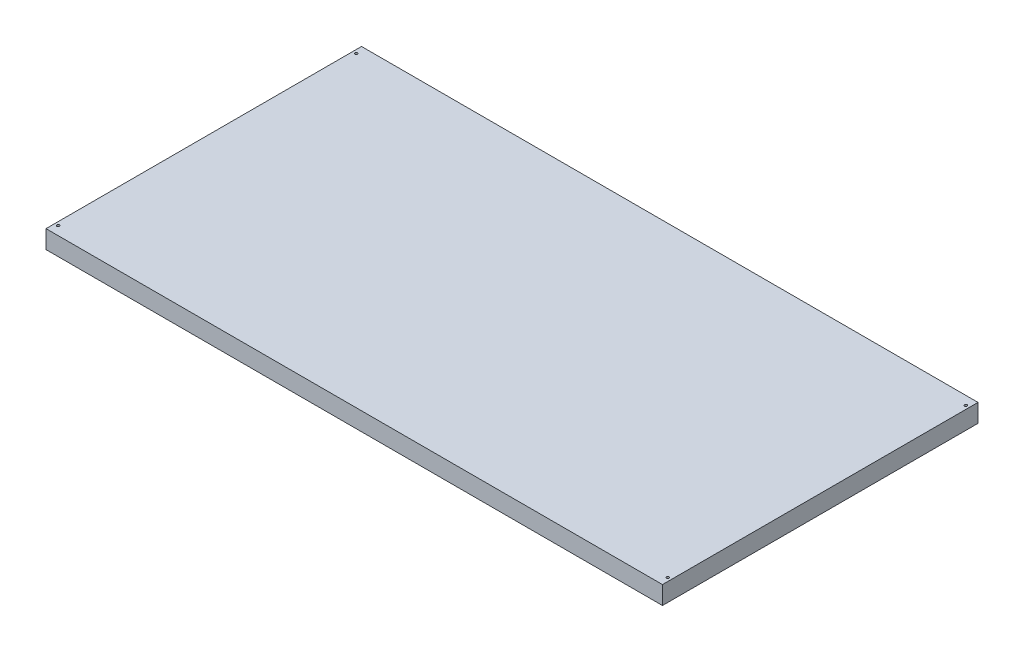
from build123d import *

# Parameters (mm, degrees)
SKETCH1_W           = 1559.306
SKETCH1_H           = 798.068
BOSS_EXTRUDE1_DEPTH = 45.974
SKETCH2_R           = 3.302
CUT_EXTRUDE1_DEPTH  = 46.974


with BuildPart() as part:
    # Sketch1 → Boss-Extrude1 (new body)
    with BuildSketch(Plane(origin=(0, 0, 0), x_dir=(1, 0, 0), z_dir=(0, 1, 0))):
        Rectangle(SKETCH1_W, SKETCH1_H)
    extrude(amount=BOSS_EXTRUDE1_DEPTH)

    # Sketch2 → Cut-Extrude1 (cut, through all)
    with BuildSketch(Plane(origin=(0, 45.974, 0), x_dir=(1, 0, 0), z_dir=(0, 1, 0))):
        with Locations((-771.017, 377.063)):
            Circle(SKETCH2_R)
        with Locations((771.017, 377.063)):
            Circle(SKETCH2_R)
        with Locations((771.017, -377.063)):
            Circle(SKETCH2_R)
        with Locations((-771.017, -377.063)):
            Circle(SKETCH2_R)
    extrude(amount=-CUT_EXTRUDE1_DEPTH, mode=Mode.SUBTRACT)


solid = part.part
